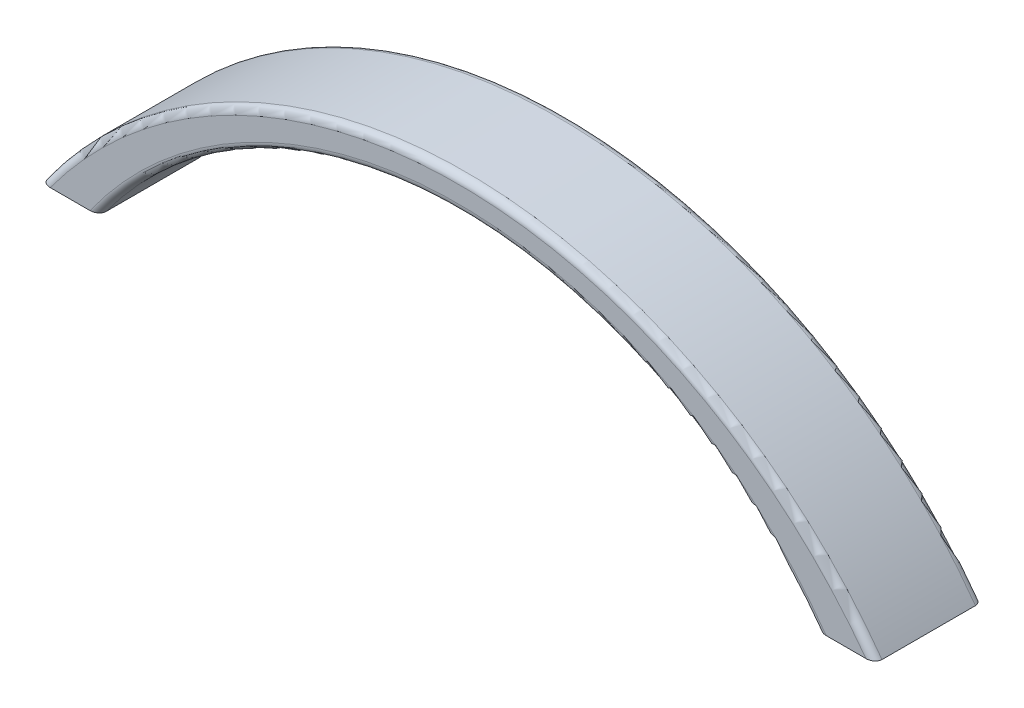
from build123d import *

# Parameters (mm, degrees)
BOSS_EXTRUDE1_DEPTH = 15
FILLET1_R           = 1


with BuildPart() as part:
    # Sketch1 → Boss-Extrude1 (new body)
    with BuildSketch(Plane.XY):
        with BuildLine():
            Line((-50, 0), (-58, 0))
            ThreePointArc((-58, 0), (0, 29.814567302), (58, 0))
            Line((58, 0), (50, 0))
            ThreePointArc((50, 0), (0, 25.447613222), (-50, 0))
        make_face()
    extrude(amount=BOSS_EXTRUDE1_DEPTH)

    # Fillet1
    fillet1_edges = [part.edges().sort_by_distance(p)[0] for p in [
        (0, 29.814567302, 15),
        (0, 25.447613222, 15),
        (0, 29.814567302, 0),
        (0, 25.447613222, 0),
    ]]
    fillet(fillet1_edges, radius=FILLET1_R)


solid = part.part
